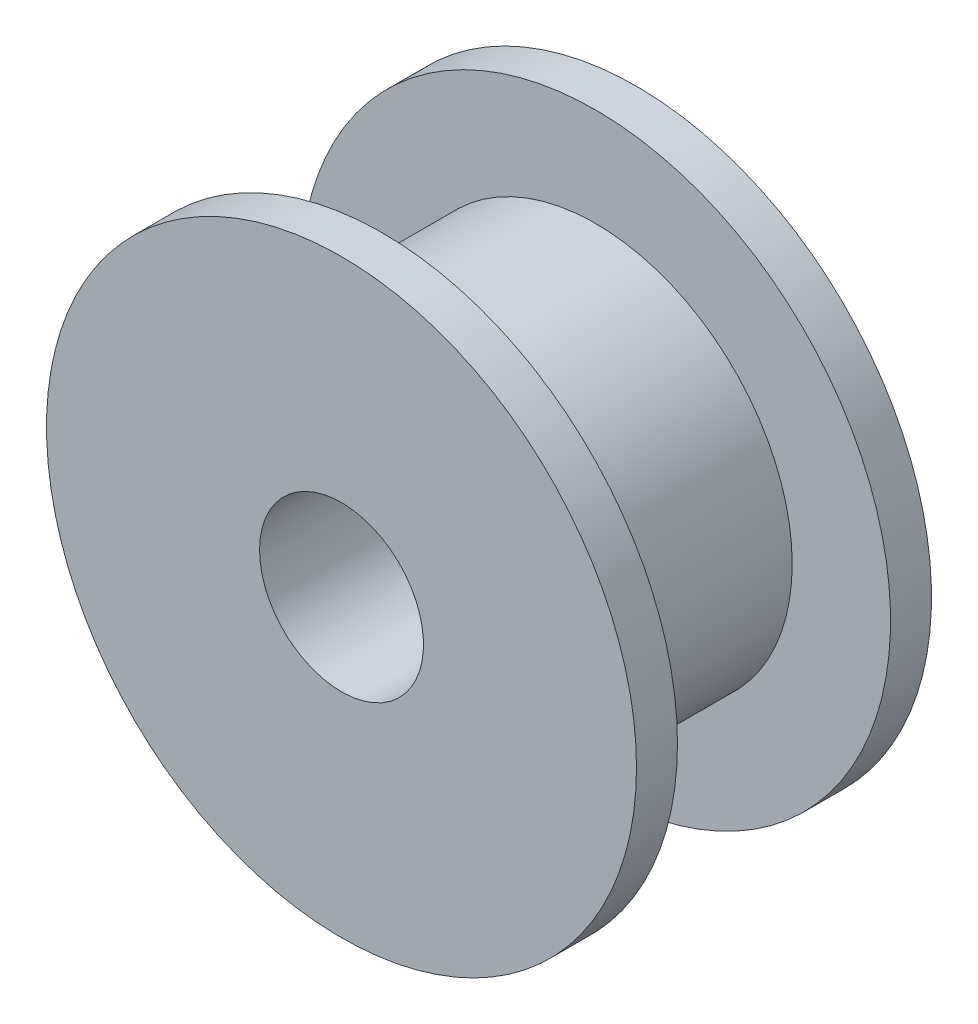
from build123d import *

# Parameters (mm, degrees)
CROQUIS1_R              = 6
SALIENTE_EXTRUIR1_DEPTH = 6.5
CROQUIS2_R              = 9
SALIENTE_EXTRUIR2_DEPTH = 1.25
CROQUIS3_R              = 9
SALIENTE_EXTRUIR3_DEPTH = 1.25
CROQUIS4_R              = 2.5
CORTAR_EXTRUIR1_DEPTH   = 10


with BuildPart() as part:
    # Croquis1 → Saliente-Extruir1 (new body)
    with BuildSketch(Plane.XY):
        Circle(CROQUIS1_R)
    extrude(amount=SALIENTE_EXTRUIR1_DEPTH)

    # Croquis2 → Saliente-Extruir2 (add)
    with BuildSketch(Plane.XY.offset(6.5)):
        Circle(CROQUIS2_R)
    extrude(amount=SALIENTE_EXTRUIR2_DEPTH)

    # Croquis3 → Saliente-Extruir3 (add)
    with BuildSketch(Plane(origin=(0, 0, 0), x_dir=(-1, 0, 0), z_dir=(0, 0, -1))):
        Circle(CROQUIS3_R)
    extrude(amount=SALIENTE_EXTRUIR3_DEPTH)

    # Croquis4 → Cortar-Extruir1 (cut, through all)
    with BuildSketch(Plane(origin=(0, 0, -1.25), x_dir=(-1, 0, 0), z_dir=(0, 0, -1))):
        Circle(CROQUIS4_R)
    extrude(amount=-CORTAR_EXTRUIR1_DEPTH, mode=Mode.SUBTRACT)


solid = part.part
